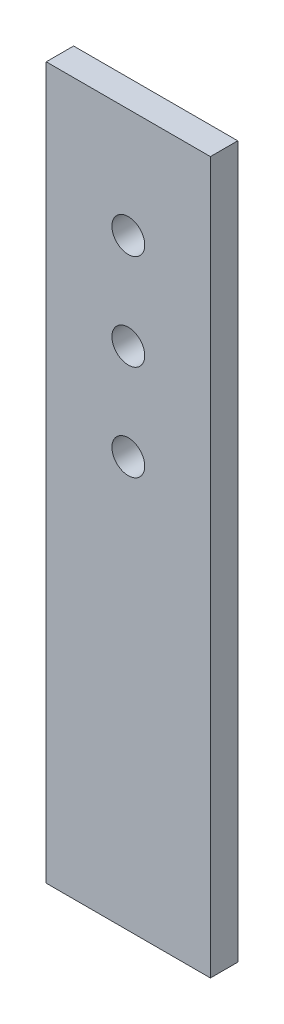
from build123d import *

# Parameters (mm, degrees)
CROQUIS1_W              = 60
CROQUIS1_H              = 260
CROQUIS1_R              = 6
SALIENTE_EXTRUIR1_DEPTH = 10


with BuildPart() as part:
    # Croquis1 → Saliente-Extruir1 (new body)
    with BuildSketch(Plane.XY):
        Rectangle(CROQUIS1_W, CROQUIS1_H)
        with Locations((0, 55)):
            Circle(CROQUIS1_R, mode=Mode.SUBTRACT)
        with Locations((0, 90)):
            Circle(CROQUIS1_R, mode=Mode.SUBTRACT)
        with Locations((0, 20)):
            Circle(CROQUIS1_R, mode=Mode.SUBTRACT)
    extrude(amount=SALIENTE_EXTRUIR1_DEPTH)


solid = part.part
